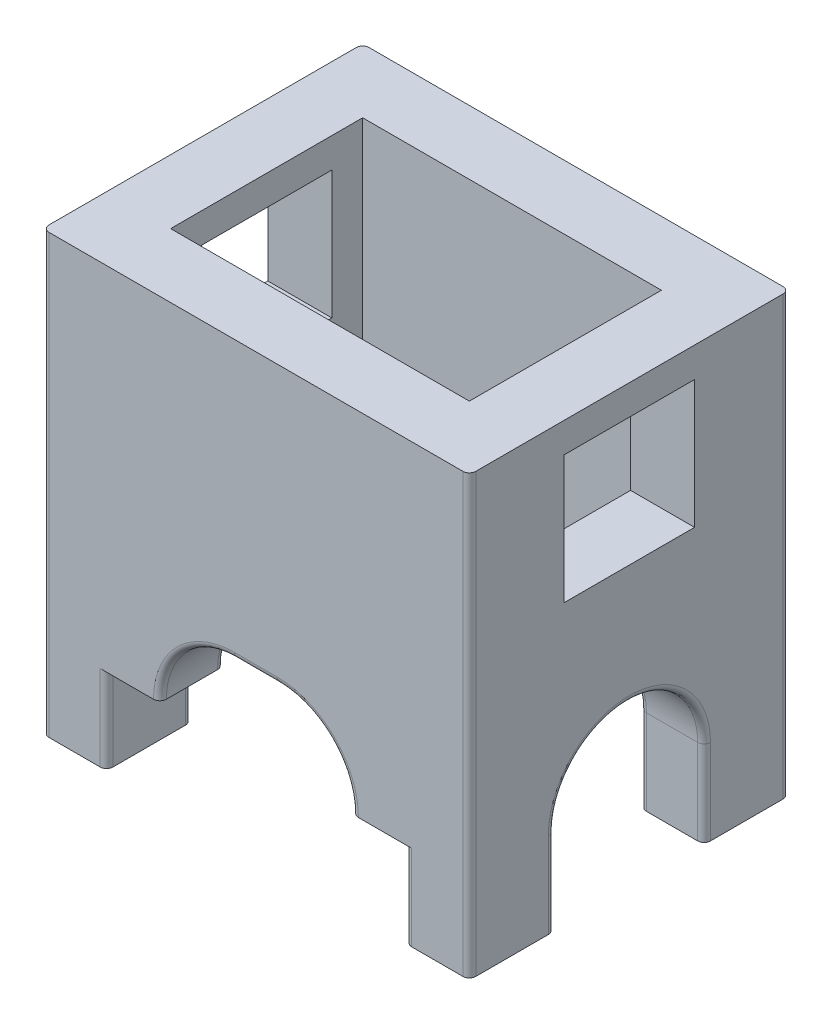
from build123d import *

# Parameters (mm, degrees)
SKETCH_1_W               = 20
SKETCH_1_H               = 15
SKETCH_1_W_2             = 14
SKETCH_1_H_2             = 9
EXTRUDE_1_DEPTH          = 16.5
SKETCH_2_W               = 6.10870136
SKETCH_2_H               = 6
CUT_EXTRUDE_1_DEPTH      = 18
CUT_EXTRUDE_1_DEPTH_BACK = 4
CUT_EXTRUDE_2_DEPTH      = 13
CUT_EXTRUDE_2_DEPTH_BACK = 4
SKETCH_5_R               = 3.5
CUT_EXTRUDE_3_DEPTH      = 18
CUT_EXTRUDE_3_DEPTH_BACK = 4
SKETCH_6_W               = 3
SKETCH_6_H               = 4
EXTRUDE_2_DEPTH          = 4
FILLET_1_R               = 0.3
FILLET_2_R               = 0.3


with BuildPart() as part:
    # Эскиз1 → Бобышка-Вытянуть1 (new body)
    with BuildSketch(Plane(origin=(0, 0, 0), x_dir=(1, 0, 0), z_dir=(0, 1, 0))):
        Rectangle(SKETCH_1_W, SKETCH_1_H)
        Rectangle(SKETCH_1_W_2, SKETCH_1_H_2, mode=Mode.SUBTRACT)
    extrude(amount=-EXTRUDE_1_DEPTH)

    # Эскиз2 → Вырез-Вытянуть1 (cut, two sides)
    with BuildSketch(Plane.ZY.offset(-7)) as cut_extrude_1_sk:
        with Locations((0, -4.4)):
            Rectangle(SKETCH_2_W, SKETCH_2_H)
    extrude(amount=CUT_EXTRUDE_1_DEPTH, mode=Mode.SUBTRACT)
    extrude(cut_extrude_1_sk.sketch, amount=-CUT_EXTRUDE_1_DEPTH_BACK, mode=Mode.SUBTRACT)

    # Эскиз4 → Вырез-Вытянуть2 (cut, two sides)
    with BuildSketch(Plane(origin=(0, 0, 4.5), x_dir=(-1, 0, 0), z_dir=(0, 0, -1))) as cut_extrude_2_sk:
        with BuildLine():
            Line((-1, -13), (1, -13))
            ThreePointArc((1, -13), (4.5, -16.5), (1, -20))
            Line((1, -20), (-1, -20))
            ThreePointArc((-1, -20), (-4.5, -16.5), (-1, -13))
        make_face()
    extrude(amount=CUT_EXTRUDE_2_DEPTH, mode=Mode.SUBTRACT)
    extrude(cut_extrude_2_sk.sketch, amount=-CUT_EXTRUDE_2_DEPTH_BACK, mode=Mode.SUBTRACT)

    # Эскиз5 → Вырез-Вытянуть3 (cut, two sides)
    with BuildSketch(Plane(origin=(-7, 0, 0), x_dir=(0, 0, -1), z_dir=(1, 0, 0))) as cut_extrude_3_sk:
        with Locations((0, -16.5)):
            Circle(SKETCH_5_R)
    extrude(amount=CUT_EXTRUDE_3_DEPTH, mode=Mode.SUBTRACT)
    extrude(cut_extrude_3_sk.sketch, amount=-CUT_EXTRUDE_3_DEPTH_BACK, mode=Mode.SUBTRACT)

    # Эскиз6 → Бобышка-Вытянуть2 (add)
    with BuildSketch(Plane.XZ.offset(16.5)):
        with Locations((-8.5, -5.5)):
            Rectangle(SKETCH_6_W, SKETCH_6_H)
        with Locations((-8.5, 5.5)):
            Rectangle(SKETCH_6_W, SKETCH_6_H)
        with Locations((8.5, 5.5)):
            Rectangle(SKETCH_6_W, SKETCH_6_H)
        with Locations((8.5, -5.5)):
            Rectangle(SKETCH_6_W, SKETCH_6_H)
    extrude(amount=EXTRUDE_2_DEPTH)

    # Скругление1
    fillet_1_edges = [part.edges().sort_by_distance(p)[0] for p in [
        (-10, -10.25, -7.5),
        (10, -10.25, -7.5),
        (10, -10.25, 7.5),
        (-10, -10.25, 7.5),
    ]]
    fillet(fillet_1_edges, radius=FILLET_1_R)

    # Скругление2
    fillet_2_edges = [part.edges().sort_by_distance(p)[0] for p in [
        (-10, -18.5, -3.5),
        (-7, -18.5, -7.5),
        (-7, -18.5, -3.5),
        (-7, -18.5, 3.5),
        (-7, -18.5, 7.5),
        (-10, -18.5, 3.5),
        (7, -18.5, 7.5),
        (7, -18.5, 3.5),
        (10, -18.5, 3.5),
        (7, -18.5, -3.5),
        (7, -18.5, -7.5),
        (10, -18.5, -3.5),
        (-3.474873734, -14.025126266, 4.5),
        (0, -13, 4.5),
        (3.474873734, -14.025126266, 4.5),
        (0, -13, 7.5),
        (3.474873734, -14.025126266, -7.5),
        (-3.474873734, -14.025126266, -7.5),
        (3.474873734, -14.025126266, -4.5),
        (3.474873734, -14.025126266, 7.5),
        (0, -13, -7.5),
        (-3.474873734, -14.025126266, -4.5),
        (-3.474873734, -14.025126266, 7.5),
        (0, -13, -4.5),
        (7, -13, 0),
        (10, -13, 0),
        (-10, -13, 0),
        (-7, -13, 0),
    ]]
    fillet(fillet_2_edges, radius=FILLET_2_R)


solid = part.part
